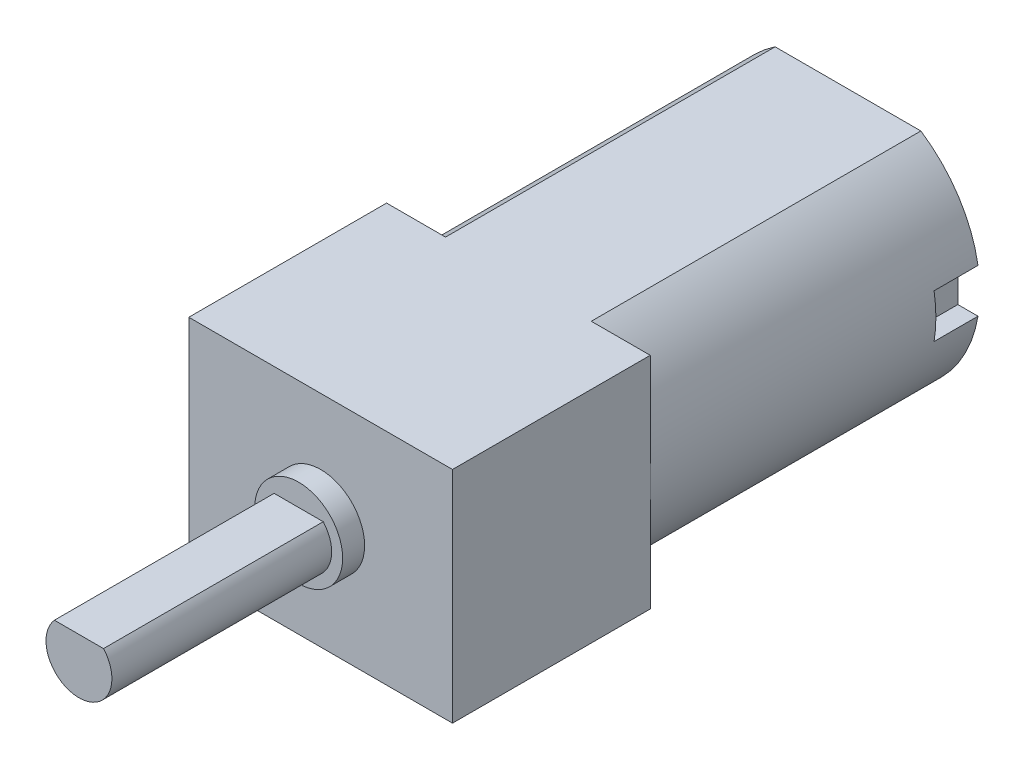
from build123d import *

# Parameters (mm, degrees)
EXTRUDE_1_DEPTH     = 15
SKETCH_3_R          = 2.5
EXTRUDE_2_DEPTH     = 1
CUT_EXTRUDE_1_DEPTH = 2
EXTRUDE_3_DEPTH     = 9
SKETCH_7_R          = 2
EXTRUDE_4_DEPTH     = 1
EXTRUDE_5_DEPTH     = 10


with BuildPart() as part:
    # 草图1 → 凸台-拉伸1 (new body)
    with BuildSketch(Plane.XY):
        with BuildLine():
            Line((-3.31662479, 0), (3.31662479, 0))
            ThreePointArc((3.31662479, 0), (6, 5), (3.31662479, 10))
            Line((3.31662479, 10), (-3.31662479, 10))
            ThreePointArc((-3.31662479, 10), (-6, 5), (-3.31662479, 0))
        make_face()
    extrude(amount=EXTRUDE_1_DEPTH)

    # 草图3 → 凸台-拉伸2 (add)
    with BuildSketch(Plane.XY):
        with Locations((0, 5)):
            Circle(SKETCH_3_R)
    extrude(amount=-EXTRUDE_2_DEPTH)

    # 草图4 → 切除-拉伸1 (cut)
    with BuildSketch(Plane.XY):
        with BuildLine():
            Line((5, 6), (5.916079783, 6))
            ThreePointArc((5.916079783, 6), (6, 5), (5.916079783, 4))
            Line((5.916079783, 4), (5, 4))
            Line((5, 4), (5, 5))
            Line((5, 5), (5, 6))
        make_face()
        with BuildLine():
            Line((-5, 4), (-5.916079783, 4))
            ThreePointArc((-5.916079783, 4), (-6, 5), (-5.916079783, 6))
            Line((-5.916079783, 6), (-5, 6))
            Line((-5, 6), (-5, 5))
            Line((-5, 5), (-5, 4))
        make_face()
    extrude(amount=CUT_EXTRUDE_1_DEPTH, mode=Mode.SUBTRACT)

    # 草图6 → 凸台-拉伸3 (add)
    with BuildSketch(Plane.XY.offset(15)):
        Polygon((0, 0), (6, 0), (6, 5), (6, 10), (-6, 10), (-6, 5), (-6, 0), align=None)
    extrude(amount=EXTRUDE_3_DEPTH)

    # 草图7 → 凸台-拉伸4 (add)
    with BuildSketch(Plane.XY.offset(24)):
        with Locations((0, 5)):
            Circle(SKETCH_7_R)
    extrude(amount=EXTRUDE_4_DEPTH)

    # 草图8 → 凸台-拉伸5 (add)
    with BuildSketch(Plane.XY.offset(25)):
        with BuildLine():
            Line((1.118033989, 6), (0, 6))
            Line((0, 6), (-1.118033989, 6))
            ThreePointArc((-1.118033989, 6), (-0.535233135, 3.598741462), (1.5, 5))
            ThreePointArc((1.5, 5), (1.401258538, 5.535233135), (1.118033989, 6))
        make_face()
    extrude(amount=EXTRUDE_5_DEPTH)


solid = part.part
